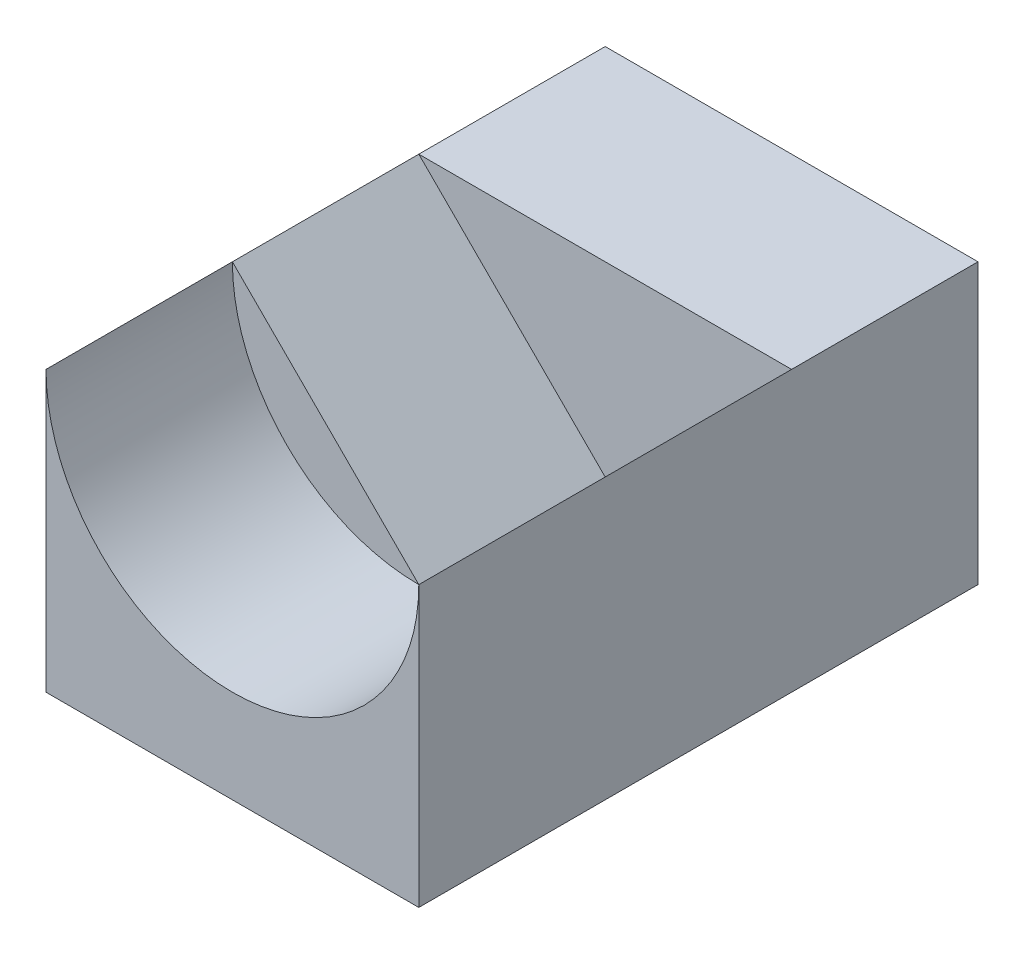
from build123d import *

# Parameters (mm, degrees)
SKETCH_1_W          = 20
SKETCH_1_H          = 30
EXTRUDE_1_DEPTH     = 15
CUT_EXTRUDE_1_DEPTH = 10
CUT_EXTRUDE_2_DEPTH = 10
SCALE_1_SCALE       = 0.2


with BuildPart() as part:
    # 草圖1 → 填料-伸長1 (new body)
    with BuildSketch(Plane(origin=(0, 0, 0), x_dir=(1, 0, 0), z_dir=(0, 1, 0))):
        Rectangle(SKETCH_1_W, SKETCH_1_H)
    extrude(amount=EXTRUDE_1_DEPTH)

    # 草圖2 → 除料-伸長1 (cut)
    with BuildSketch(Plane.XY.offset(15)):
        with BuildLine():
            Line((10, 15), (-10, 15))
            ThreePointArc((-10, 15), (0, 5), (10, 15))
        make_face()
    extrude(amount=-CUT_EXTRUDE_1_DEPTH, mode=Mode.SUBTRACT)

    # 草圖3 → 除料-伸長2 (cut)
    with BuildSketch(Plane.XY.offset(5)):
        Polygon((-10, 15), (0, 5), (10, 15), align=None)
    extrude(amount=-CUT_EXTRUDE_2_DEPTH, mode=Mode.SUBTRACT)


with BuildPart() as part_1:
    # 縮放比例1: scaled about (0, 6.056435148, -2.443220664)
    add(part.part.scale(SCALE_1_SCALE).moved(Location((0, 4.845148118, -1.954576531))))


solid = part_1.part
